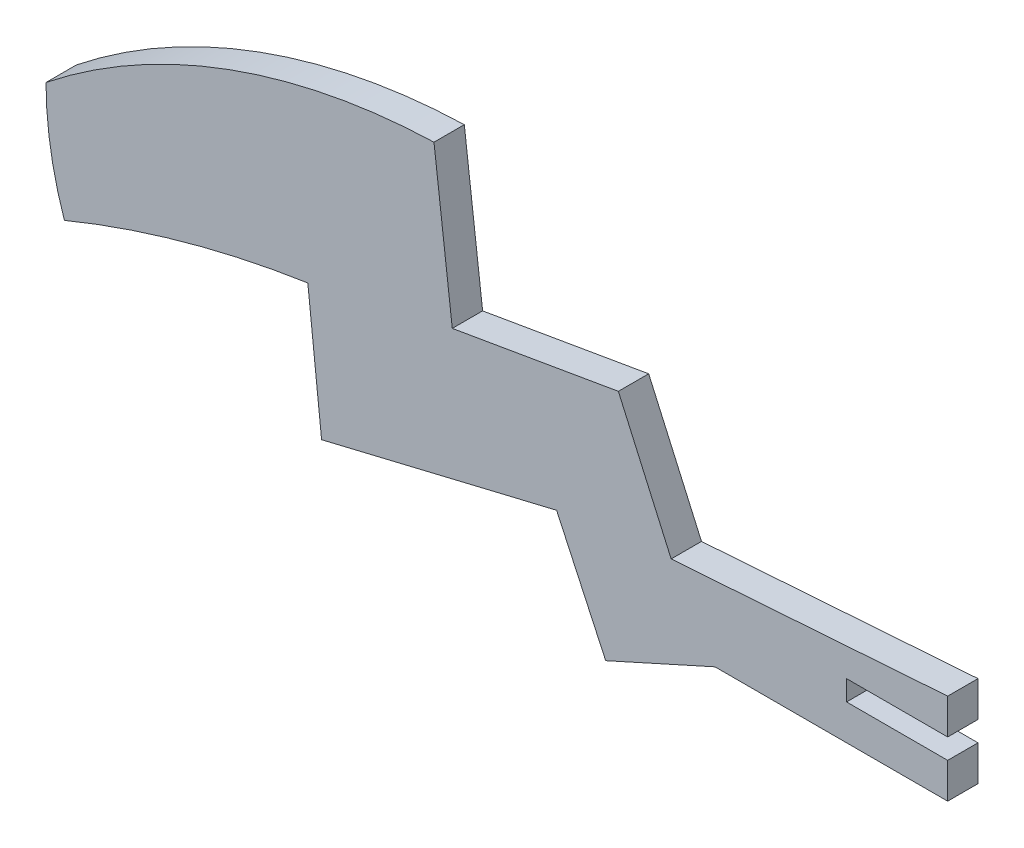
from build123d import *

# Parameters (mm, degrees)
SALIENTE_EXTRUIR1_DEPTH = 3


with BuildPart() as part:
    # Model → Saliente-Extruir1 (new body)
    with BuildSketch(Plane.XY):
        with BuildLine():
            Line((78.512585392, 8.480394017), (67.503193542, 8.480394017))
            Line((67.503193542, 8.480394017), (55.493801692, 8.480394017))
            Line((55.493801692, 8.480394017), (44.687089166, 3.603222324))
            Line((44.687089166, 3.603222324), (39.831918887, 14.06059302))
            Line((39.831918887, 14.06059302), (16.586059329, 8.480394017))
            Line((16.586059329, 8.480394017), (15.223673977, 21.22645362))
            ThreePointArc((15.223673977, 21.22645362), (2.983166863, 18.616670486), (-8.854222662, 14.552535688))
            ThreePointArc((-8.854222662, 14.552535688), (-10.212878112, 19.928241742), (-10.673926914, 25.453781916))
            ThreePointArc((-10.673926914, 25.453781916), (7.377127931, 35.592311556), (27.703067566, 39.527605983))
            Line((27.703067566, 39.527605983), (29.512585392, 24.480394017))
            Line((29.512585392, 24.480394017), (45.938881991, 27.30453113))
            Line((45.938881991, 27.30453113), (51.161258051, 15.555534113))
            Line((51.161258051, 15.555534113), (78.512585392, 17.480394017))
            Line((78.512585392, 17.480394017), (78.512585392, 13.980394017))
            Line((78.512585392, 13.980394017), (68.512585392, 13.980394017))
            Line((68.512585392, 13.980394017), (68.512585392, 11.980394017))
            Line((68.512585392, 11.980394017), (78.512585392, 11.980394017))
            Line((78.512585392, 11.980394017), (78.512585392, 8.480394017))
        make_face()
    extrude(amount=SALIENTE_EXTRUIR1_DEPTH)


solid = part.part
